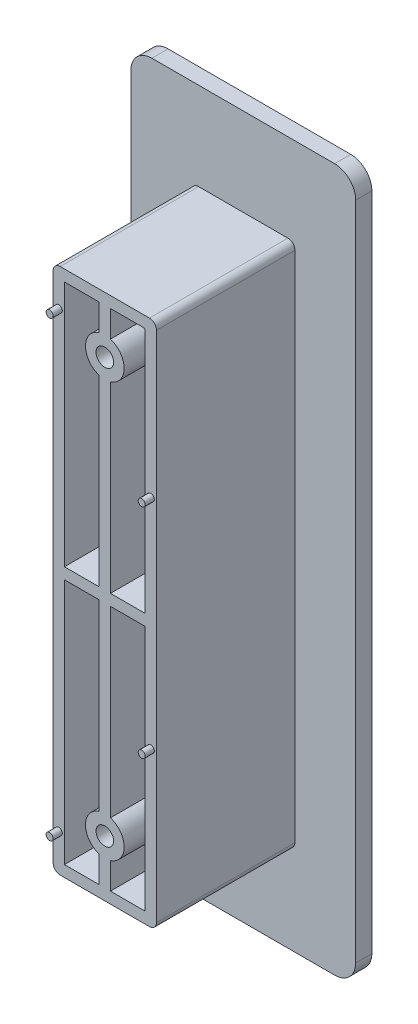
from build123d import *

# Parameters (mm, degrees)
EXTRUDE_2_DEPTH     = 22
EXTRUDE_3_DEPTH     = 2.3
SHELL_1_T           = -1.6
EXTRUDE_4_DEPTH     = 20.4
EXTRUDE_START       = -20.4
SKETCH_4_R          = 2.75
SKETCH_4_R_2        = 1.25
EXTRUDE_5_DEPTH     = 20.4
SKETCH_5_R          = 1.25
CUT_EXTRUDE_1_DEPTH = 22
SKETCH_6_R          = 0.5
EXTRUDE_6_DEPTH     = 1.3


with BuildPart() as part:
    # 스케치1 → 보스-돌출2 (new body)
    with BuildSketch(Plane(origin=(0, 0, 0), x_dir=(0, 1, 0), z_dir=(0, 0, 1))):
        with BuildLine():
            Line((-36.5, 7.35), (36.5, 7.35))
            ThreePointArc((36.5, 7.35), (37.207106781, 7.057106781), (37.5, 6.35))
            Line((37.5, 6.35), (37.5, -6.35))
            ThreePointArc((37.5, -6.35), (37.207106781, -7.057106781), (36.5, -7.35))
            Line((36.5, -7.35), (-36.5, -7.35))
            ThreePointArc((-36.5, -7.35), (-37.207106781, -7.057106781), (-37.5, -6.35))
            Line((-37.5, -6.35), (-37.5, 6.35))
            ThreePointArc((-37.5, 6.35), (-37.207106781, 7.057106781), (-36.5, 7.35))
        make_face()
    extrude(amount=EXTRUDE_2_DEPTH)

    # 스케치1<5> → 보스-돌출3 (add)
    with BuildSketch(Plane(origin=(0, 0, 0), x_dir=(0, 1, 0), z_dir=(0, 0, 1))):
        with BuildLine():
            Line((-47, 16), (47, 16))
            ThreePointArc((47, 16), (49.121320344, 15.121320344), (50, 13))
            Line((50, 13), (50, -13))
            ThreePointArc((50, -13), (49.121320344, -15.121320344), (47, -16))
            Line((47, -16), (-47, -16))
            ThreePointArc((-47, -16), (-49.121320344, -15.121320344), (-50, -13))
            Line((-50, -13), (-50, 13))
            ThreePointArc((-50, 13), (-49.121320344, 15.121320344), (-47, 16))
        make_face()
        with BuildLine():
            Line((-36.5, 7.35), (36.5, 7.35))
            ThreePointArc((36.5, 7.35), (37.207106781, 7.057106781), (37.5, 6.35))
            Line((37.5, 6.35), (37.5, -6.35))
            ThreePointArc((37.5, -6.35), (37.207106781, -7.057106781), (36.5, -7.35))
            Line((36.5, -7.35), (-36.5, -7.35))
            ThreePointArc((-36.5, -7.35), (-37.207106781, -7.057106781), (-37.5, -6.35))
            Line((-37.5, -6.35), (-37.5, 6.35))
            ThreePointArc((-37.5, 6.35), (-37.207106781, 7.057106781), (-36.5, 7.35))
        make_face(mode=Mode.SUBTRACT)
    extrude(amount=EXTRUDE_3_DEPTH)

    # 쉘1
    shell_1_openings = [part.faces().sort_by_distance(p)[0] for p in [
        (0, 0, 22),
    ]]
    offset(amount=SHELL_1_T, openings=shell_1_openings, kind=Kind.INTERSECTION)

    # 스케치3 → 보스-돌출4 (add)
    with BuildSketch(Plane.XY.offset(1.6)):
        Polygon((0.8, 35.9), (0.8, 0.8), (5.75, 0.8), (5.75, -0.8), (0.8, -0.8), (0.8, -35.9), (-0.8, -35.9), (-0.8, -0.8), (-5.75, -0.8), (-5.75, 0.8), (-0.8, 0.8), (-0.8, 35.9), align=None)
    extrude(amount=EXTRUDE_4_DEPTH)

    # 스케치4 → 보스-돌출5 (add)
    with BuildSketch(Plane.XY.offset(22).offset(EXTRUDE_START)):
        with Locations((0, 29.5)):
            Circle(SKETCH_4_R)
        with Locations((0, 29.5)):
            Circle(SKETCH_4_R_2, mode=Mode.SUBTRACT)
        with Locations((0, -29.5)):
            Circle(SKETCH_4_R)
    extrude(amount=EXTRUDE_5_DEPTH)

    # 스케치5 → 컷-돌출1 (cut)
    with BuildSketch(Plane.XY.offset(22)):
        with Locations((0, -29.5)):
            Circle(SKETCH_5_R)
        with Locations((0, 29.5)):
            Circle(SKETCH_5_R)
    extrude(amount=-CUT_EXTRUDE_1_DEPTH, mode=Mode.SUBTRACT)

    # 스케치6 → 보스-돌출6 (add)
    with BuildSketch(Plane.XY.offset(22)):
        with Locations((-6.55, -32.2)):
            Circle(SKETCH_6_R)
        with Locations((6.55, -15.5)):
            Circle(SKETCH_6_R)
        with Locations((-6.55, 32.2)):
            Circle(SKETCH_6_R)
        with Locations((6.55, 15.5)):
            Circle(SKETCH_6_R)
    extrude(amount=EXTRUDE_6_DEPTH)


solid = part.part
